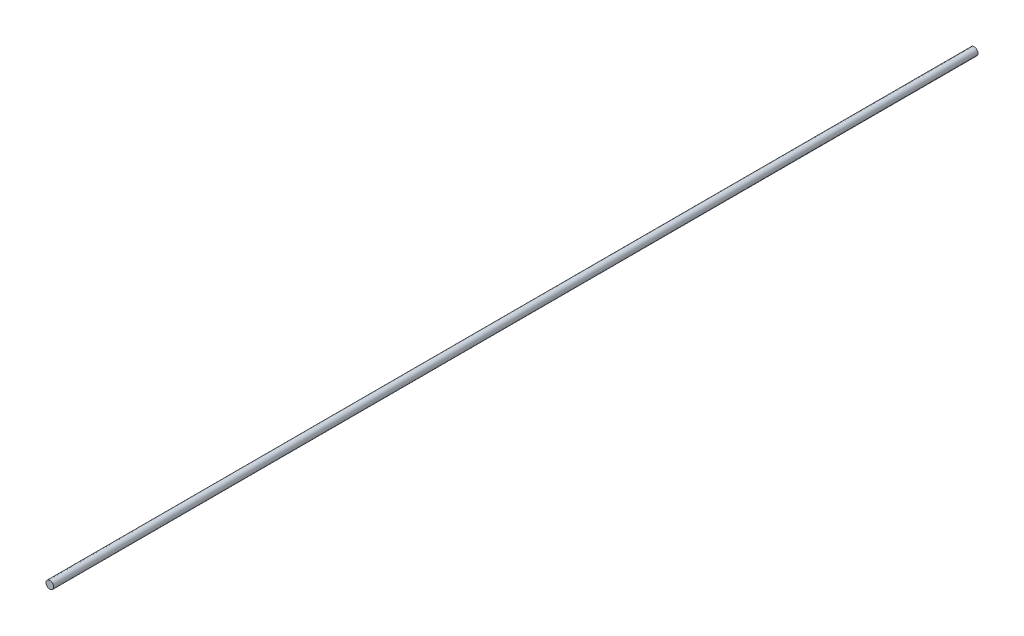
from build123d import *

# Parameters (mm, degrees)
SKETCH1_R           = 1
BOSS_EXTRUDE1_DEPTH = 241.88


with BuildPart() as part:
    # Sketch1 → Boss-Extrude1 (new body)
    with BuildSketch(Plane.XY):
        Circle(SKETCH1_R)
    extrude(amount=BOSS_EXTRUDE1_DEPTH)


solid = part.part
